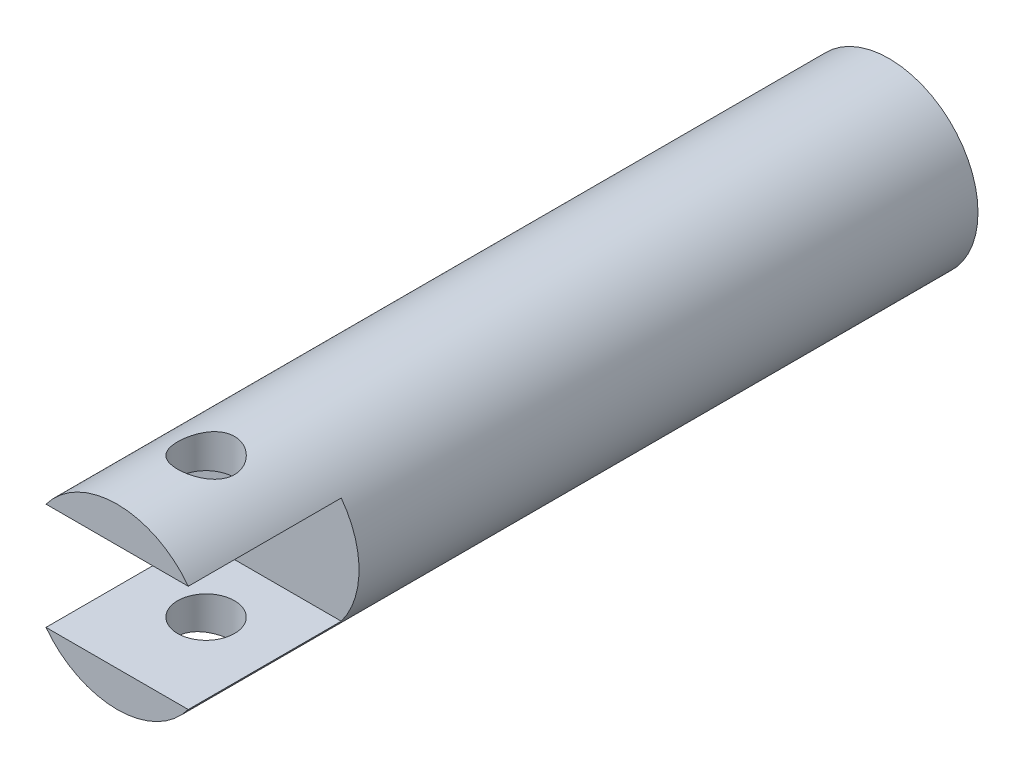
from build123d import *

# Parameters (mm, degrees)
SKETCH1_R               = 25
BOSS_EXTRUDE1_DEPTH     = 217
SKETCH2_R               = 19
CUT_EXTRUDE1_DEPTH      = 10
SKETCH3_R               = 14
CUT_EXTRUDE2_DEPTH      = 10
SKETCH4_W               = 43
SKETCH4_H               = 30
CUT_EXTRUDE3_DEPTH      = 26
CUT_EXTRUDE3_DEPTH_BACK = 26
SKETCH5_R               = 8
CUT_EXTRUDE4_DEPTH      = 26
CUT_EXTRUDE4_DEPTH_BACK = 26


with BuildPart() as part:
    # Sketch1 → Boss-Extrude1 (new body)
    with BuildSketch(Plane.XY):
        Circle(SKETCH1_R)
    extrude(amount=BOSS_EXTRUDE1_DEPTH)

    # Sketch2 → Cut-Extrude1 (cut)
    with BuildSketch(Plane(origin=(0, 0, 0), x_dir=(-1, 0, 0), z_dir=(0, 0, -1))):
        Circle(SKETCH2_R)
    extrude(amount=-CUT_EXTRUDE1_DEPTH, mode=Mode.SUBTRACT)

    # Sketch3 → Cut-Extrude2 (cut)
    with BuildSketch(Plane(origin=(0, 0, 10), x_dir=(-1, 0, 0), z_dir=(0, 0, -1))):
        Circle(SKETCH3_R)
    extrude(amount=-CUT_EXTRUDE2_DEPTH, mode=Mode.SUBTRACT)

    # Sketch4 → Cut-Extrude3 (cut, two sides)
    with BuildSketch(Plane(origin=(0, 0, 0), x_dir=(0, 0, -1), z_dir=(1, 0, 0))) as cut_extrude3_sk:
        with Locations((-195.5, 0)):
            Rectangle(SKETCH4_W, SKETCH4_H)
    extrude(amount=CUT_EXTRUDE3_DEPTH, mode=Mode.SUBTRACT)
    extrude(cut_extrude3_sk.sketch, amount=-CUT_EXTRUDE3_DEPTH_BACK, mode=Mode.SUBTRACT)

    # Sketch5 → Cut-Extrude4 (cut, two sides)
    with BuildSketch(Plane(origin=(0, 0, 0), x_dir=(1, 0, 0), z_dir=(0, 1, 0))) as cut_extrude4_sk:
        with Locations((0, -192)):
            Circle(SKETCH5_R)
    extrude(amount=CUT_EXTRUDE4_DEPTH, mode=Mode.SUBTRACT)
    extrude(cut_extrude4_sk.sketch, amount=-CUT_EXTRUDE4_DEPTH_BACK, mode=Mode.SUBTRACT)


solid = part.part
